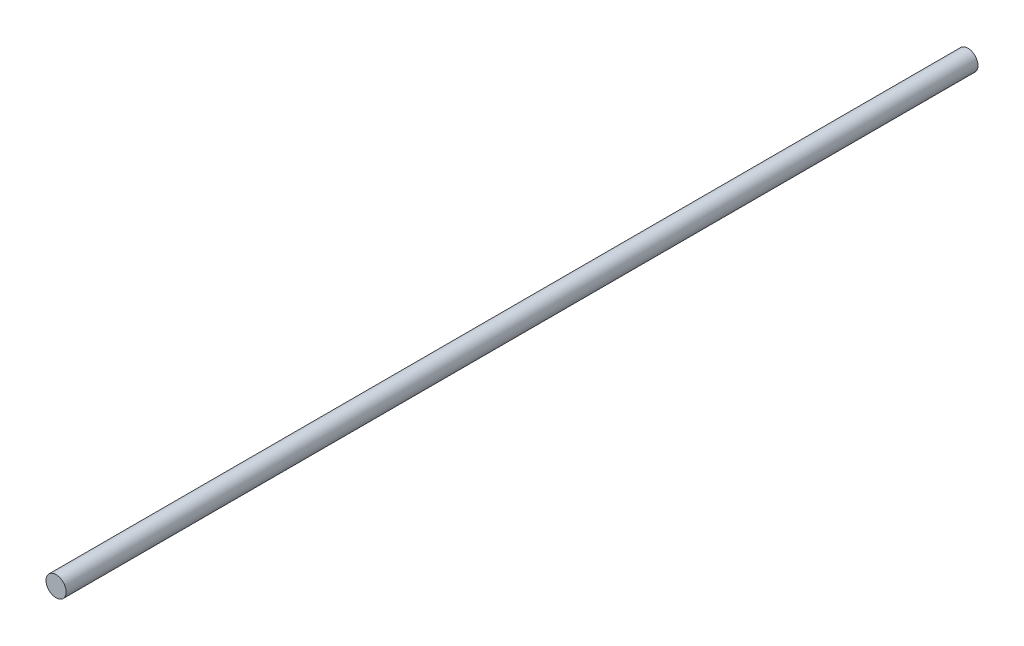
from build123d import *

# Parameters (mm, degrees)
SKETCH_1_R      = 4
EXTRUDE_1_DEPTH = 362


with BuildPart() as part:
    # 草图1 → 凸台-拉伸1 (new body)
    with BuildSketch(Plane.XY):
        Circle(SKETCH_1_R)
    extrude(amount=EXTRUDE_1_DEPTH)


solid = part.part
